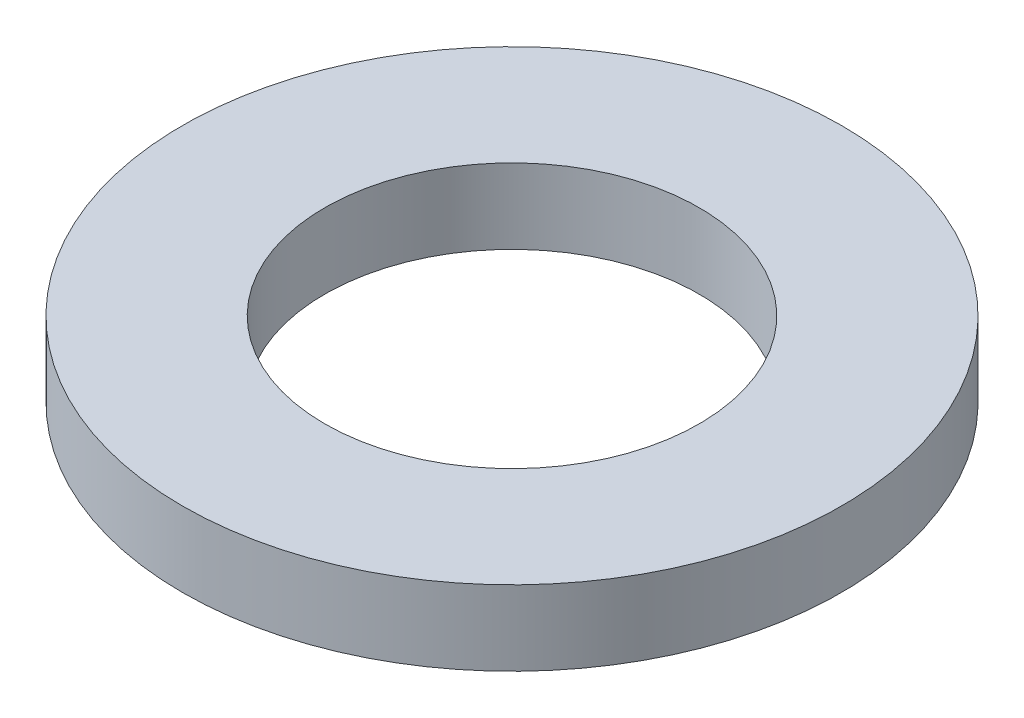
from build123d import *

# Parameters (mm, degrees)
CROQUIS1_R              = 22
CROQUIS1_R_2            = 12.5
SALIENTE_EXTRUIR1_DEPTH = 5


with BuildPart() as part:
    # Croquis1 → Saliente-Extruir1 (new body)
    with BuildSketch(Plane(origin=(0, 0, 0), x_dir=(1, 0, 0), z_dir=(0, 1, 0))):
        Circle(CROQUIS1_R)
        Circle(CROQUIS1_R_2, mode=Mode.SUBTRACT)
    extrude(amount=SALIENTE_EXTRUIR1_DEPTH)


solid = part.part
